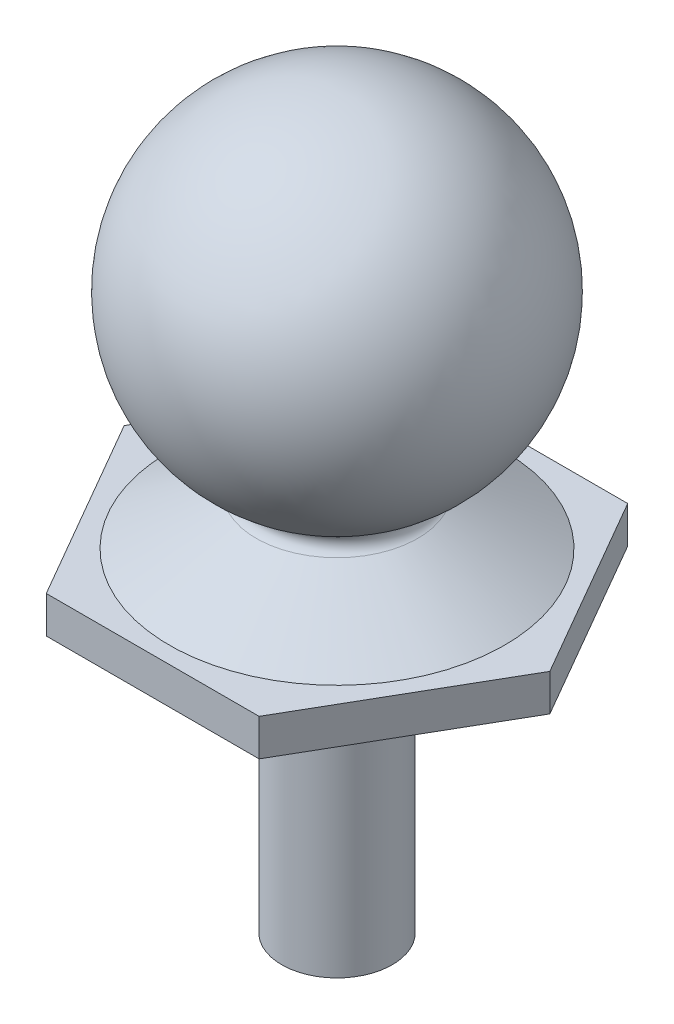
from build123d import *

# Parameters (mm, degrees)
BOSS_EXTRUDE1_DEPTH = 1


with BuildPart() as part:
    # Sketch1 → Revolve1 (revolve)
    with BuildSketch(Plane.XY):
        with BuildLine():
            Line((2.192086479, -4.705335748), (4.85, -6.209624758))
            Line((4.85, -6.209624758), (5, -6.209624758))
            Line((5, -6.209624758), (5, -7.037825562))
            Line((5, -7.037825562), (1.5, -7.037825562))
            Line((1.5, -7.037825562), (1.5, -15.067944601))
            Line((1.5, -15.067944601), (0, -15.067944601))
            Line((0, -15.067944601), (0, 4.709624758))
            ThreePointArc((0, 4.709624758), (4.570709757, 1.135419606), (2.203858582, -4.162159622))
            ThreePointArc((2.203858582, -4.162159622), (2.035645477, -4.430229616), (2.192086479, -4.705335748))
        make_face()
    revolve(axis=Axis((0, 4.709624758, 0), (0, -1, 0)))

    # Sketch3 → Boss-Extrude1 (add)
    with BuildSketch(Plane.XZ.offset(7.037825562)):
        Polygon((5.773502692, 0), (2.886751346, 5), (-2.886751346, 5), (-5.773502692, 0), (-2.886751346, -5), (2.886751346, -5), align=None)
    extrude(amount=-BOSS_EXTRUDE1_DEPTH)


solid = part.part
